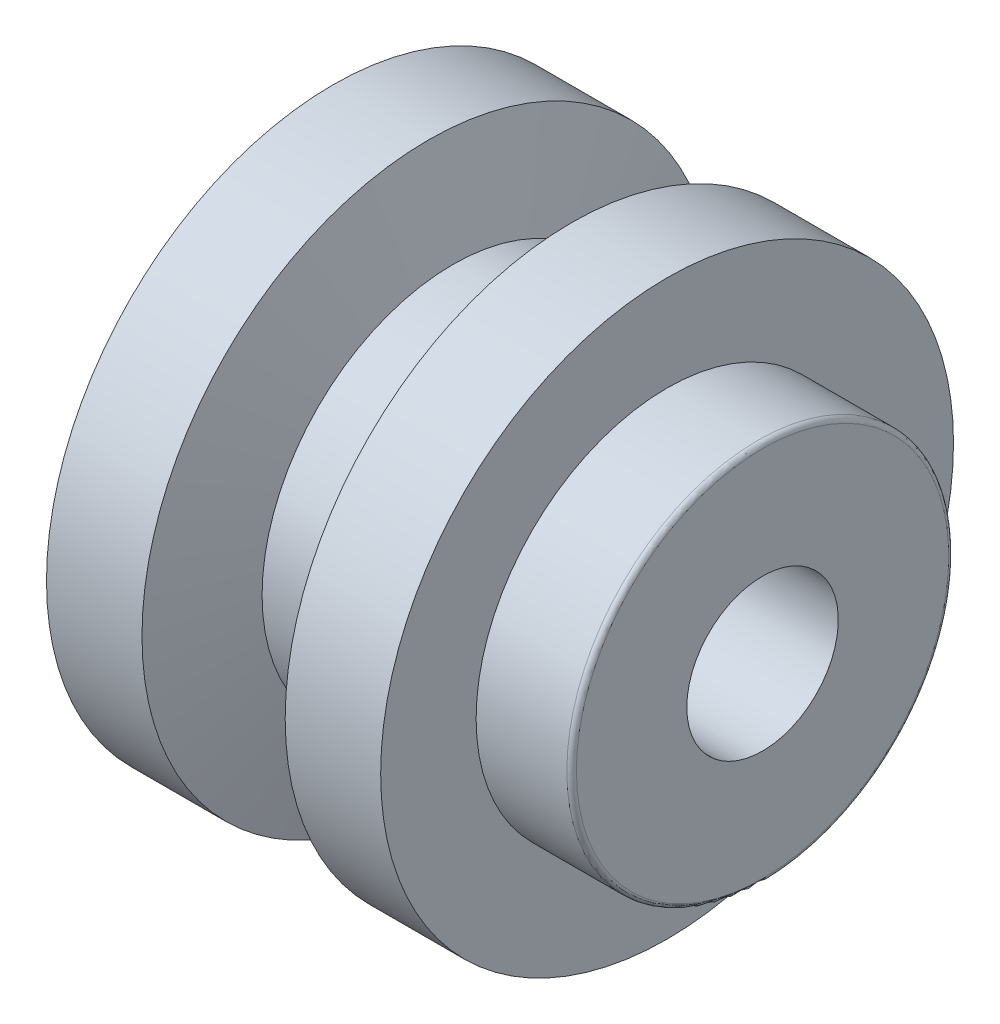
from build123d import *


with BuildPart() as part:
    # Sketch1 → Revolve1 (revolve)
    with BuildSketch(Plane.XY):
        with BuildLine():
            Line((0, -17.935), (0, -30))
            Line((0, -30), (10, -30))
            Line((10, -30), (12.580192505, -20))
            Line((12.580192505, -20), (22.320508076, -20))
            Line((22.320508076, -20), (25, -30))
            Line((25, -30), (35, -30))
            Line((35, -30), (35, -20))
            Line((35, -20), (44.5, -20))
            ThreePointArc((44.5, -20), (44.853553391, -19.853553391), (45, -19.5))
            Line((45, -19.5), (45, -7.935))
            Line((45, -7.935), (2.5, -7.935))
            Line((2.5, -7.935), (0, -17.935))
        make_face()
    revolve(axis=Axis((0, 0, 0), (1, 0, 0)))


solid = part.part
